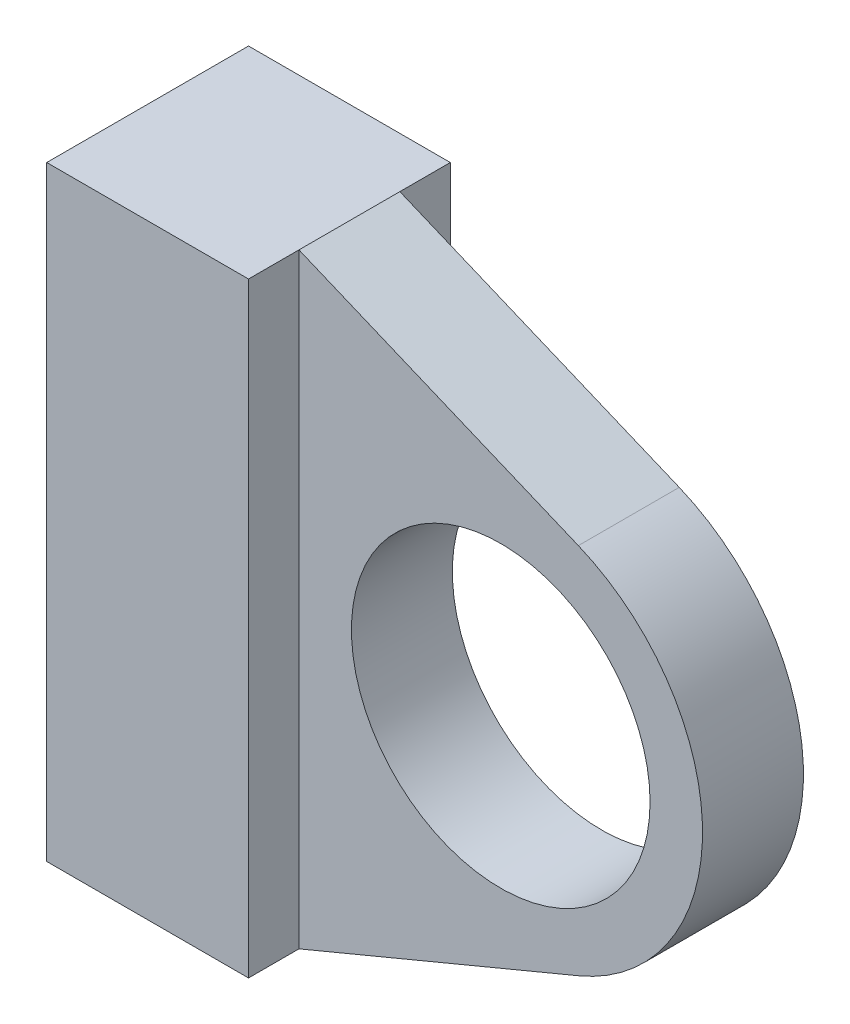
from build123d import *

# Parameters (mm, degrees)
SKETCH1_R           = 9.398
BOSS_EXTRUDE1_DEPTH = 3.175
SKETCH2_W           = 12.7
SKETCH2_H           = 38.1
BOSS_EXTRUDE2_DEPTH = 6.35


with BuildPart() as part:
    # Sketch1 → Boss-Extrude1 (new body, symmetric)
    with BuildSketch(Plane.XY):
        with BuildLine():
            Line((-601.427317331, -1564.55033403), (-601.427317331, -1602.65033403))
            Line((-601.427317331, -1602.65033403), (-588.727317331, -1602.65033403))
            Line((-588.727317331, -1602.65033403), (-571.142701946, -1595.323410953))
            ThreePointArc((-571.142701946, -1595.323410953), (-563.327317331, -1583.60033403), (-571.142701946, -1571.877257107))
            Line((-571.142701946, -1571.877257107), (-588.727317331, -1564.55033403))
            Line((-588.727317331, -1564.55033403), (-601.427317331, -1564.55033403))
        make_face()
        with Locations((-576.027317331, -1583.60033403)):
            Circle(SKETCH1_R, mode=Mode.SUBTRACT)
    extrude(amount=BOSS_EXTRUDE1_DEPTH, both=True)

    # Sketch2 → Boss-Extrude2 (add, symmetric)
    with BuildSketch(Plane.XY):
        with Locations((-595.077317331, -1583.60033403)):
            Rectangle(SKETCH2_W, SKETCH2_H)
    extrude(amount=BOSS_EXTRUDE2_DEPTH, both=True)


solid = part.part
